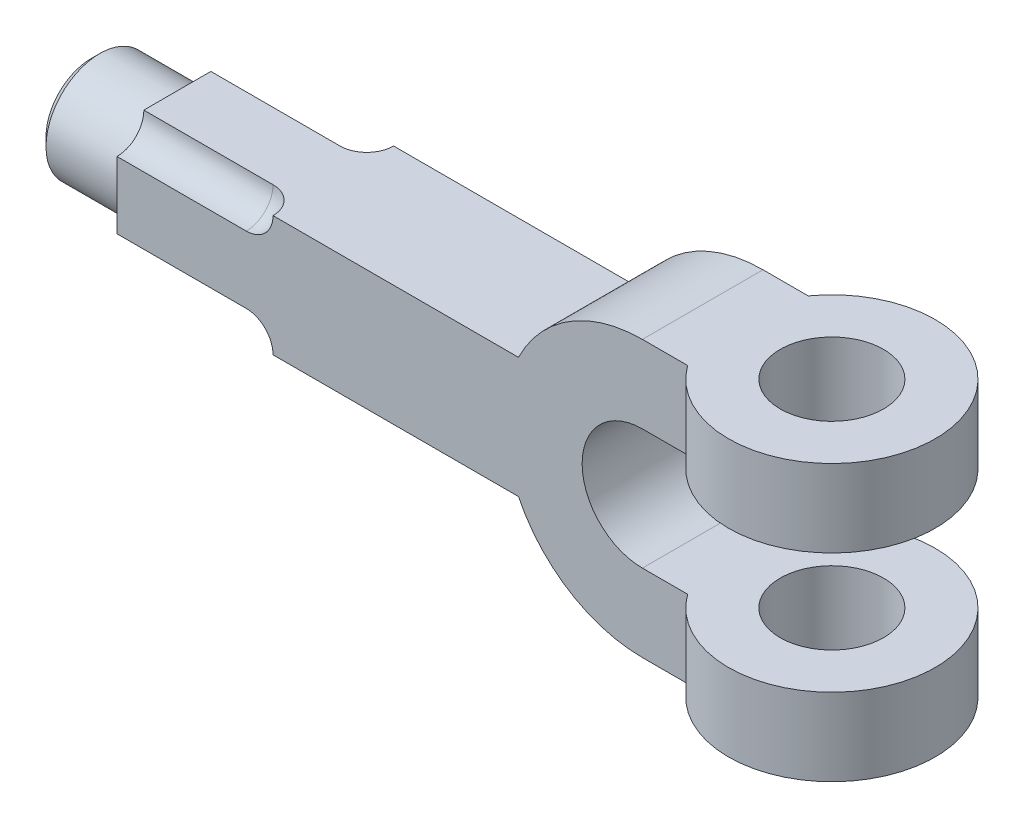
from build123d import *

# Parameters (mm, degrees)
BOSS_EXTRUDE1_DEPTH = 14
SKETCH2_R           = 24
SKETCH2_R_2         = 12
BOSS_EXTRUDE2_DEPTH = 18
BOSS_EXTRUDE3_REACH = 178
SKETCH3_W           = 28
SKETCH3_H           = 28
SKETCH5_R           = 12.5
BOSS_EXTRUDE4_DEPTH = 20
CHAMFER1_SIZE       = 2


with BuildPart() as part:
    # Sketch1 → Boss-Extrude1 (new body, symmetric)
    with BuildSketch(Plane.XY):
        with BuildLine():
            Line((0, 32), (18, 32))
            Line((18, 32), (18, 14))
            Line((18, 14), (0, 14))
            ThreePointArc((0, 14), (-14, 0), (0, -14))
            Line((0, -14), (18, -14))
            Line((18, -14), (18, -32))
            Line((18, -32), (0, -32))
            ThreePointArc((0, -32), (-32, 0), (0, 32))
        make_face()
    extrude(amount=BOSS_EXTRUDE1_DEPTH, both=True)

    # Sketch2 → Boss-Extrude2 (add)
    with BuildSketch(Plane(origin=(0, 32, 0), x_dir=(1, 0, 0), z_dir=(0, 1, 0))):
        with Locations((30, 0)):
            Circle(SKETCH2_R)
        with Locations((30, 0)):
            Circle(SKETCH2_R_2, mode=Mode.SUBTRACT)
    boss_extrude2 = extrude(amount=-BOSS_EXTRUDE2_DEPTH)

    # Mirror1: Boss-Extrude2 across plane
    add(boss_extrude2.mirror(Plane.ZX))

    # Sketch3 → Boss-Extrude3 (add, up to next)
    with BuildSketch(Plane(origin=(-122, 0, 0), x_dir=(0, 0, -1), z_dir=(1, 0, 0)), mode=Mode.PRIVATE) as boss_extrude3_sk1:
        Rectangle(SKETCH3_W, SKETCH3_H)
    boss_extrude3_tool1 = extrude(boss_extrude3_sk1.sketch, amount=BOSS_EXTRUDE3_REACH, mode=Mode.PRIVATE) - part.part
    add(boss_extrude3_tool1.solids().sort_by_distance((-122, 0, 0))[0])

    # Sketch4 → Cut-Revolve1 (revolve, cut)
    with BuildSketch(Plane.XY.offset(14)):
        with BuildLine():
            Line((-122, 14), (-122, 7.78))
            Line((-122, 7.78), (-92, 7.78))
            ThreePointArc((-92, 7.78), (-87.601795821, 9.601795821), (-85.78, 14))
            Line((-85.78, 14), (-122, 14))
        make_face()
    cut_revolve1 = revolve(axis=Axis((500000, 14, 14), (-1, 0, 0)), mode=Mode.SUBTRACT)

    # Mirror2: Cut-Revolve1 across plane
    add(cut_revolve1.mirror(Plane.XY), mode=Mode.SUBTRACT)

    # Mirror3: Cut-Revolve1 across plane
    add(cut_revolve1.mirror(Plane.ZX), mode=Mode.SUBTRACT)

    # Mirror3 copy 1 sketch → Mirror3 copy 1 (revolve, cut)
    with BuildSketch(Plane(origin=(0, 0, -14), x_dir=(1, 0, 0), z_dir=(0, 0, -1))):
        with BuildLine():
            Line((-122, 14), (-122, 7.78))
            Line((-122, 7.78), (-92, 7.78))
            ThreePointArc((-92, 7.78), (-87.601795821, 9.601795821), (-85.78, 14))
            Line((-85.78, 14), (-122, 14))
        make_face()
    revolve(axis=Axis((500000, -14, -14), (-1, 0, 0)), mode=Mode.SUBTRACT)

    # Sketch5 → Boss-Extrude4 (add)
    with BuildSketch(Plane.ZY.offset(122)):
        Circle(SKETCH5_R)
    extrude(amount=BOSS_EXTRUDE4_DEPTH)

    # Chamfer1
    chamfer1_edges = [part.edges().sort_by_distance(p)[0] for p in [
        (-142, 0, -12.5),
    ]]
    chamfer(chamfer1_edges, length=CHAMFER1_SIZE)


solid = part.part
